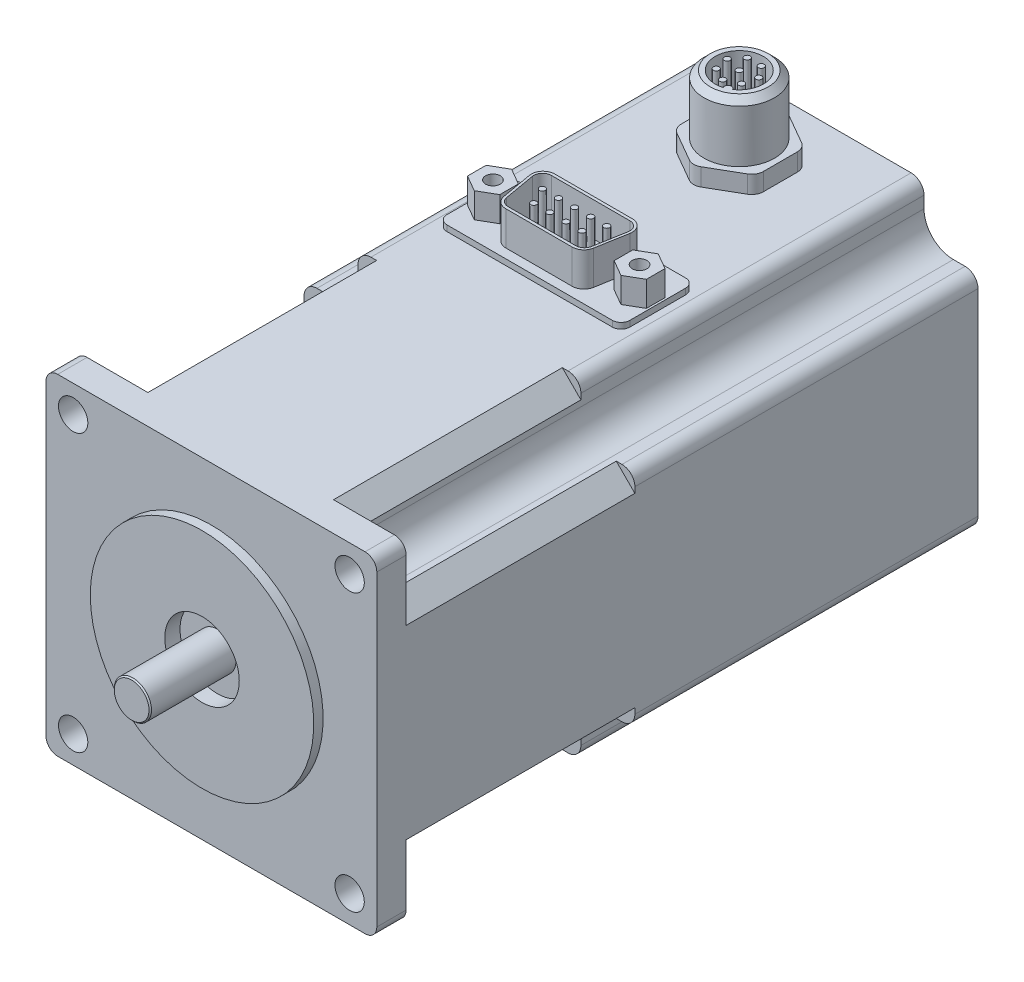
from build123d import *

# Parameters (mm, degrees)
BOSS_EXTRUDE1_DEPTH = 70.5
SKETCH4_R           = 2.5
CUT_EXTRUDE1_DEPTH  = 5
SKETCH5_R           = 2.5
CUT_EXTRUDE2_DEPTH  = 5
SKETCH6_R           = 2.5
CUT_EXTRUDE3_DEPTH  = 5
SKETCH7_R           = 2.5
CUT_EXTRUDE4_DEPTH  = 5
SKETCH3_W           = 75.2
SKETCH3_H           = 75.2
CUT_EXTRUDE5_DEPTH  = 65.5
SKETCH8_W           = 75.2
SKETCH8_H           = 75.2
CUT_EXTRUDE6_DEPTH  = 39
BOSS_EXTRUDE2_DEPTH = 32
BOSS_EXTRUDE3_DEPTH = 1
BOSS_EXTRUDE4_DEPTH = 6.8
SKETCH12_R          = 0.5
CUT_EXTRUDE7_DEPTH  = 5.8
SKETCH13_R          = 1.25
BOSS_EXTRUDE5_DEPTH = 5.3
SKETCH14_R          = 1.25
BOSS_EXTRUDE6_DEPTH = 5.3
SKETCH15_W          = 38
SKETCH15_H          = 17
CUT_EXTRUDE8_DEPTH  = 0.1
BOSS_EXTRUDE7_DEPTH = 3
SKETCH18_R          = 0.5
CUT_EXTRUDE9_DEPTH  = 8


with BuildPart() as part:
    # Sketch1 → Revolve1 (revolve)
    with BuildSketch(Plane(origin=(0, 0, 0), x_dir=(1, 0, 0), z_dir=(0, 1, 0))):
        Polygon((0, 0), (19.05, 0), (19.05, -1.6), (3.175, -1.6), (3.175, -13.6), (0, -13.6), align=None)
    revolve(axis=Axis((0, 0, 13.6), (0, 0, -1)))

    # Sketch2 → Boss-Extrude1 (add)
    with BuildSketch(Plane.XY):
        with BuildLine():
            Line((-26.2, -28.2), (26.2, -28.2))
            ThreePointArc((26.2, -28.2), (27.614213562, -27.614213562), (28.2, -26.2))
            Line((28.2, -26.2), (28.2, 26.2))
            ThreePointArc((28.2, 26.2), (27.614213562, 27.614213562), (26.2, 28.2))
            Line((26.2, 28.2), (-26.2, 28.2))
            ThreePointArc((-26.2, 28.2), (-27.614213562, 27.614213562), (-28.2, 26.2))
            Line((-28.2, 26.2), (-28.2, -26.2))
            ThreePointArc((-28.2, -26.2), (-27.614213562, -27.614213562), (-26.2, -28.2))
        make_face()
    extrude(amount=-BOSS_EXTRUDE1_DEPTH)

    # Sketch4 → Cut-Extrude1 (cut)
    with BuildSketch(Plane.XY):
        with Locations((23.57, -23.57)):
            Circle(SKETCH4_R)
    extrude(amount=-CUT_EXTRUDE1_DEPTH, mode=Mode.SUBTRACT)

    # Sketch5 → Cut-Extrude2 (cut)
    with BuildSketch(Plane.XY):
        with Locations((23.57, 23.57)):
            Circle(SKETCH5_R)
    extrude(amount=-CUT_EXTRUDE2_DEPTH, mode=Mode.SUBTRACT)

    # Sketch6 → Cut-Extrude3 (cut)
    with BuildSketch(Plane.XY):
        with Locations((-23.57, -23.57)):
            Circle(SKETCH6_R)
    extrude(amount=-CUT_EXTRUDE3_DEPTH, mode=Mode.SUBTRACT)

    # Sketch7 → Cut-Extrude4 (cut)
    with BuildSketch(Plane.XY):
        with Locations((-23.57, 23.57)):
            Circle(SKETCH7_R)
    extrude(amount=-CUT_EXTRUDE4_DEPTH, mode=Mode.SUBTRACT)

    # Sketch3 → Cut-Extrude5 (cut)
    with BuildSketch(Plane.XY.offset(-5)):
        Rectangle(SKETCH3_W, SKETCH3_H)
        with BuildLine():
            Line((-26, -19), (-24, -19))
            ThreePointArc((-24, -19), (-20.464466094, -20.464466094), (-19, -24))
            Line((-19, -24), (-19, -26))
            ThreePointArc((-19, -26), (-18.355634919, -27.555634919), (-16.8, -28.2))
            Line((-16.8, -28.2), (16.8, -28.2))
            ThreePointArc((16.8, -28.2), (18.355634919, -27.555634919), (19, -26))
            Line((19, -26), (19, -24))
            ThreePointArc((19, -24), (20.464466094, -20.464466094), (24, -19))
            Line((24, -19), (26, -19))
            ThreePointArc((26, -19), (27.555634919, -18.355634919), (28.2, -16.8))
            Line((28.2, -16.8), (28.2, 16.8))
            ThreePointArc((28.2, 16.8), (27.555634919, 18.355634919), (26, 19))
            Line((26, 19), (24, 19))
            ThreePointArc((24, 19), (20.464466094, 20.464466094), (19, 24))
            Line((19, 24), (19, 26))
            ThreePointArc((19, 26), (18.355634919, 27.555634919), (16.8, 28.2))
            Line((16.8, 28.2), (-16.8, 28.2))
            ThreePointArc((-16.8, 28.2), (-18.355634919, 27.555634919), (-19, 26))
            Line((-19, 26), (-19, 24))
            ThreePointArc((-19, 24), (-20.464466094, 20.464466094), (-24, 19))
            Line((-24, 19), (-26, 19))
            ThreePointArc((-26, 19), (-27.555634919, 18.355634919), (-28.2, 16.8))
            Line((-28.2, 16.8), (-28.2, -16.8))
            ThreePointArc((-28.2, -16.8), (-27.555634919, -18.355634919), (-26, -19))
        make_face(mode=Mode.SUBTRACT)
    extrude(amount=-CUT_EXTRUDE5_DEPTH, mode=Mode.SUBTRACT)

    # Sketch8 → Cut-Extrude6 (cut)
    with BuildSketch(Plane.XY.offset(-5)):
        Rectangle(SKETCH8_W, SKETCH8_H)
        Polygon((-28.2, -15.825631329), (-15.825631329, -28.2), (15.825631329, -28.2), (28.2, -15.825631329), (28.2, 15.825631329), (15.825631329, 28.2), (-15.825631329, 28.2), (-28.2, 15.825631329), align=None, mode=Mode.SUBTRACT)
    extrude(amount=-CUT_EXTRUDE6_DEPTH, mode=Mode.SUBTRACT)

    # Sketch9 → Boss-Extrude2 (add)
    with BuildSketch(Plane.XY.offset(-70.5)):
        with BuildLine():
            Line((-26, -19), (-24, -19))
            ThreePointArc((-24, -19), (-20.464466094, -20.464466094), (-19, -24))
            Line((-19, -24), (-19, -26))
            ThreePointArc((-19, -26), (-18.355634919, -27.555634919), (-16.8, -28.2))
            Line((-16.8, -28.2), (16.8, -28.2))
            ThreePointArc((16.8, -28.2), (18.355634919, -27.555634919), (19, -26))
            Line((19, -26), (19, -24))
            ThreePointArc((19, -24), (20.464466094, -20.464466094), (24, -19))
            Line((24, -19), (26, -19))
            ThreePointArc((26, -19), (27.555634919, -18.355634919), (28.2, -16.8))
            Line((28.2, -16.8), (28.2, 16.8))
            ThreePointArc((28.2, 16.8), (27.555634919, 18.355634919), (26, 19))
            Line((26, 19), (24, 19))
            ThreePointArc((24, 19), (20.464466094, 20.464466094), (19, 24))
            Line((19, 24), (19, 26))
            ThreePointArc((19, 26), (18.355634919, 27.555634919), (16.8, 28.2))
            Line((16.8, 28.2), (-16.8, 28.2))
            ThreePointArc((-16.8, 28.2), (-18.355634919, 27.555634919), (-19, 26))
            Line((-19, 26), (-19, 24))
            ThreePointArc((-19, 24), (-20.464466094, 20.464466094), (-24, 19))
            Line((-24, 19), (-26, 19))
            ThreePointArc((-26, 19), (-27.555634919, 18.355634919), (-28.2, 16.8))
            Line((-28.2, 16.8), (-28.2, -16.8))
            ThreePointArc((-28.2, -16.8), (-27.555634919, -18.355634919), (-26, -19))
        make_face()
    extrude(amount=-BOSS_EXTRUDE2_DEPTH)

    # Sketch10 → Boss-Extrude3 (add)
    with BuildSketch(Plane(origin=(0, 28.2, 0), x_dir=(1, 0, 0), z_dir=(0, 1, 0))):
        with BuildLine():
            Line((-15.6, 65.25), (-15.6, 55.75))
            ThreePointArc((-15.6, 55.75), (-15.160660172, 54.689339828), (-14.1, 54.25))
            Line((-14.1, 54.25), (14.1, 54.25))
            ThreePointArc((14.1, 54.25), (15.160660172, 54.689339828), (15.6, 55.75))
            Line((15.6, 55.75), (15.6, 65.25))
            ThreePointArc((15.6, 65.25), (15.160660172, 66.310660172), (14.1, 66.75))
            Line((14.1, 66.75), (-14.1, 66.75))
            ThreePointArc((-14.1, 66.75), (-15.160660172, 66.310660172), (-15.6, 65.25))
        make_face()
    extrude(amount=BOSS_EXTRUDE3_DEPTH)

    # Sketch11 → Boss-Extrude4 (add)
    with BuildSketch(Plane(origin=(0, 28.2, 0), x_dir=(1, 0, 0), z_dir=(0, 1, 0))):
        with BuildLine():
            Line((-8.569543901, 62.802703645), (-7.635010904, 57.502703645))
            ThreePointArc((-7.635010904, 57.502703645), (-6.950970617, 56.317911114), (-5.665395398, 55.85))
            Line((-5.665395398, 55.85), (5.665395398, 55.85))
            ThreePointArc((5.665395398, 55.85), (6.950970617, 56.317911114), (7.635010904, 57.502703645))
            Line((7.635010904, 57.502703645), (8.569543901, 62.802703645))
            ThreePointArc((8.569543901, 62.802703645), (8.132017282, 64.435575219), (6.599928395, 65.15))
            Line((6.599928395, 65.15), (-6.599928395, 65.15))
            ThreePointArc((-6.599928395, 65.15), (-8.132017282, 64.435575219), (-8.569543901, 62.802703645))
        make_face()
    extrude(amount=BOSS_EXTRUDE4_DEPTH)

    # Sketch12 → Cut-Extrude7 (cut)
    with BuildSketch(Plane(origin=(0, 29.2, 0), x_dir=(1, 0, 0), z_dir=(0, 1, 0))):
        with BuildLine():
            Line((-8.173016821, 62.889527734), (-7.238483823, 57.589527733))
            ThreePointArc((-7.238483823, 57.589527733), (-6.725453608, 56.700933335), (-5.761272194, 56.35))
            Line((-5.761272194, 56.35), (5.761272194, 56.35))
            ThreePointArc((5.761272194, 56.35), (6.725453608, 56.700933335), (7.238483823, 57.589527733))
            Line((7.238483823, 57.589527733), (8.173016821, 62.889527734))
            ThreePointArc((8.173016821, 62.889527734), (7.844871856, 64.114181415), (6.695805192, 64.65))
            Line((6.695805192, 64.65), (-6.695805192, 64.65))
            ThreePointArc((-6.695805192, 64.65), (-7.844871856, 64.114181415), (-8.173016821, 62.889527734))
        make_face()
        with Locations((5.48, 61.92)):
            Circle(SKETCH12_R, mode=Mode.SUBTRACT)
        with Locations((4.11, 59.08)):
            Circle(SKETCH12_R, mode=Mode.SUBTRACT)
        with Locations((2.74, 61.92)):
            Circle(SKETCH12_R, mode=Mode.SUBTRACT)
        with Locations((1.37, 59.08)):
            Circle(SKETCH12_R, mode=Mode.SUBTRACT)
        with Locations((0, 61.92)):
            Circle(SKETCH12_R, mode=Mode.SUBTRACT)
        with Locations((-1.37, 59.08)):
            Circle(SKETCH12_R, mode=Mode.SUBTRACT)
        with Locations((-2.74, 61.92)):
            Circle(SKETCH12_R, mode=Mode.SUBTRACT)
        with Locations((-4.11, 59.08)):
            Circle(SKETCH12_R, mode=Mode.SUBTRACT)
        with Locations((-5.48, 61.92)):
            Circle(SKETCH12_R, mode=Mode.SUBTRACT)
    extrude(amount=CUT_EXTRUDE7_DEPTH, mode=Mode.SUBTRACT)

    # Sketch13 → Boss-Extrude5 (add)
    with BuildSketch(Plane(origin=(0, 28.2, 0), x_dir=(1, 0, 0), z_dir=(0, 1, 0))):
        Polygon((9.75, 58.91228676), (12.5, 57.324573519), (15.25, 58.91228676), (15.25, 62.08771324), (12.5, 63.675426481), (9.75, 62.08771324), align=None)
        with Locations((12.5, 60.5)):
            Circle(SKETCH13_R, mode=Mode.SUBTRACT)
    extrude(amount=BOSS_EXTRUDE5_DEPTH)

    # Sketch14 → Boss-Extrude6 (add)
    with BuildSketch(Plane(origin=(0, 28.2, 0), x_dir=(1, 0, 0), z_dir=(0, 1, 0))):
        Polygon((-15.25, 58.91228676), (-12.5, 57.324573519), (-9.75, 58.91228676), (-9.75, 62.08771324), (-12.5, 63.675426481), (-15.25, 62.08771324), align=None)
        with Locations((-12.5, 60.5)):
            Circle(SKETCH14_R, mode=Mode.SUBTRACT)
    extrude(amount=BOSS_EXTRUDE6_DEPTH)

    # Sketch15 → Cut-Extrude8 (cut)
    with BuildSketch(Plane.XY.offset(-102.5)):
        Rectangle(SKETCH15_W, SKETCH15_H)
    extrude(amount=CUT_EXTRUDE8_DEPTH, mode=Mode.SUBTRACT)

    # Sketch16 → Boss-Extrude7 (add)
    with BuildSketch(Plane(origin=(0, 28.2, 0), x_dir=(1, 0, 0), z_dir=(0, 1, 0))):
        with BuildLine():
            Line((-6, 85.381197846), (-1, 82.494446501))
            ThreePointArc((-1, 82.494446501), (0, 82.226497308), (1, 82.494446501))
            Line((1, 82.494446501), (6, 85.381197846))
            ThreePointArc((6, 85.381197846), (6.732050808, 86.113248654), (7, 87.113248654))
            Line((7, 87.113248654), (7, 92.886751346))
            ThreePointArc((7, 92.886751346), (6.732050808, 93.886751346), (6, 94.618802154))
            Line((6, 94.618802154), (1, 97.505553499))
            ThreePointArc((1, 97.505553499), (0, 97.773502692), (-1, 97.505553499))
            Line((-1, 97.505553499), (-6, 94.618802154))
            ThreePointArc((-6, 94.618802154), (-6.732050808, 93.886751346), (-7, 92.886751346))
            Line((-7, 92.886751346), (-7, 87.113248654))
            ThreePointArc((-7, 87.113248654), (-6.732050808, 86.113248654), (-6, 85.381197846))
        make_face()
    extrude(amount=BOSS_EXTRUDE7_DEPTH)

    # Sketch17 → Revolve2 (revolve)
    with BuildSketch(Plane(origin=(0, 0, 0), x_dir=(0, 0, -1), z_dir=(1, 0, 0))):
        Polygon((90, 30.2), (84, 30.2), (84, 40.1265), (85.0735, 41.2), (90, 41.2), align=None)
    revolve(axis=Axis((0, 41.2, -90), (0, -1, 0)))

    # Sketch18 → Cut-Extrude9 (cut)
    with BuildSketch(Plane(origin=(0, 41.2, 0), x_dir=(1, 0, 0), z_dir=(0, 1, 0))):
        with BuildLine():
            ThreePointArc((2.255635044, 86.576243211), (-1.732734873, 93.715861927), (1.172855605, 86.071334867))
            ThreePointArc((1.172855605, 86.071334867), (1.43690209, 86.918553524), (2.255635044, 86.576243211))
        make_face()
        with Locations((-0.034905681, 87.200217581)):
            Circle(SKETCH18_R, mode=Mode.SUBTRACT)
        with Locations((2.167194703, 88.227073854)):
            Circle(SKETCH18_R, mode=Mode.SUBTRACT)
        with Locations((-2.210721375, 88.281654575)):
            Circle(SKETCH18_R, mode=Mode.SUBTRACT)
        with Locations((0, 90)):
            Circle(SKETCH18_R, mode=Mode.SUBTRACT)
        with Locations((2.737353273, 90.588979676)):
            Circle(SKETCH18_R, mode=Mode.SUBTRACT)
        with Locations((-2.721818784, 90.657040721)):
            Circle(SKETCH18_R, mode=Mode.SUBTRACT)
        with Locations((1.246228996, 92.507371789)):
            Circle(SKETCH18_R, mode=Mode.SUBTRACT)
        with Locations((-1.183331133, 92.537661804)):
            Circle(SKETCH18_R, mode=Mode.SUBTRACT)
    extrude(amount=-CUT_EXTRUDE9_DEPTH, mode=Mode.SUBTRACT)

    # Sketch19 → Cut-Revolve1 (revolve, cut)
    with BuildSketch(Plane(origin=(0, 0, 0), x_dir=(0, 0, -1), z_dir=(1, 0, 0))):
        Polygon((-13.6, 6.35), (-13.6, 2.962867966), (-13.387867966, 3.175), (1, 3.175), (1, 6.35), align=None)
    revolve(axis=Axis((0, 0, -50), (0, 0, 1)), mode=Mode.SUBTRACT)


solid = part.part
